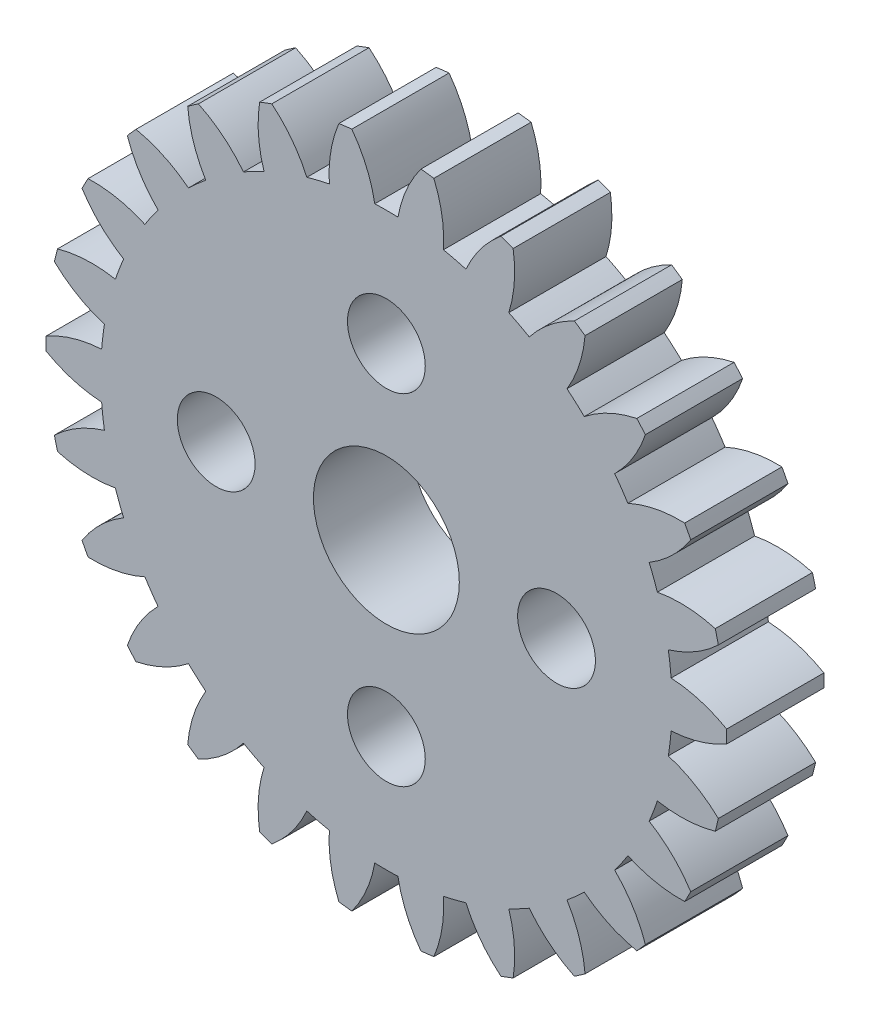
from build123d import *

# Parameters (mm, degrees)
SKETCH_1_R               = 14
EXTRUDE_1_DEPTH          = 4
CUT_EXTRUDE_1_DEPTH      = 4
PATTERN_CIRCULAR_1_COUNT = 26
CUT_EXTRUDE_2_REACH      = 6
SKETCH_3_R               = 3
SKETCH_3_R_2             = 1.6


with BuildPart() as part:
    # 草圖1 → 填料-伸長1 (new body)
    with BuildSketch(Plane.XY):
        Circle(SKETCH_1_R)
    extrude(amount=EXTRUDE_1_DEPTH)

    # 草圖2 → 除料-伸長1 (cut)
    with BuildSketch(Plane.XY.offset(4)):
        with BuildLine():
            ThreePointArc((-1.421594657, 13.927636865), (0, 14), (1.421594657, 13.927636865))
            ThreePointArc((1.421594657, 13.927636865), (0.822322703, 12.888806427), (0.476978653, 11.74031479))
            ThreePointArc((0.476978653, 11.74031479), (0, 11.75), (-0.476978653, 11.74031479))
            ThreePointArc((-0.476978653, 11.74031479), (-0.822322703, 12.888806427), (-1.421594657, 13.927636865))
        make_face()
    cut_extrude_1 = extrude(amount=-CUT_EXTRUDE_1_DEPTH, mode=Mode.SUBTRACT)

    # 環狀複製排列1: 除料-伸長1 ×26 about axis
    pattern_circular_1_axis = Axis((0, 0, 0), (0, 0, 1))
    for i in range(1, PATTERN_CIRCULAR_1_COUNT):
        add(cut_extrude_1.rotate(pattern_circular_1_axis, i * 360 / PATTERN_CIRCULAR_1_COUNT), mode=Mode.SUBTRACT)

    # 草圖3 → 除料-伸長2 (cut, up to next)
    with BuildSketch(Plane.XY.offset(4), mode=Mode.PRIVATE) as cut_extrude_2_sk1:
        Circle(SKETCH_3_R)
    cut_extrude_2_tool1 = extrude(cut_extrude_2_sk1.sketch, amount=-CUT_EXTRUDE_2_REACH, mode=Mode.PRIVATE) & part.part
    add(cut_extrude_2_tool1.solids().sort_by_distance((0, 0, 4))[0], mode=Mode.SUBTRACT)
    # 草圖3 → 除料-伸長2 (cut, up to next)
    with BuildSketch(Plane.XY.offset(4), mode=Mode.PRIVATE) as cut_extrude_2_sk2:
        with Locations((0, 7)):
            Circle(SKETCH_3_R_2)
    cut_extrude_2_tool2 = extrude(cut_extrude_2_sk2.sketch, amount=-CUT_EXTRUDE_2_REACH, mode=Mode.PRIVATE) & part.part
    add(cut_extrude_2_tool2.solids().sort_by_distance((0, 7, 4))[0], mode=Mode.SUBTRACT)
    # 草圖3 → 除料-伸長2 (cut, up to next)
    with BuildSketch(Plane.XY.offset(4), mode=Mode.PRIVATE) as cut_extrude_2_sk3:
        with Locations((7, 0)):
            Circle(SKETCH_3_R_2)
    cut_extrude_2_tool3 = extrude(cut_extrude_2_sk3.sketch, amount=-CUT_EXTRUDE_2_REACH, mode=Mode.PRIVATE) & part.part
    add(cut_extrude_2_tool3.solids().sort_by_distance((7, 0, 4))[0], mode=Mode.SUBTRACT)
    # 草圖3 → 除料-伸長2 (cut, up to next)
    with BuildSketch(Plane.XY.offset(4), mode=Mode.PRIVATE) as cut_extrude_2_sk4:
        with Locations((0, -7)):
            Circle(SKETCH_3_R_2)
    cut_extrude_2_tool4 = extrude(cut_extrude_2_sk4.sketch, amount=-CUT_EXTRUDE_2_REACH, mode=Mode.PRIVATE) & part.part
    add(cut_extrude_2_tool4.solids().sort_by_distance((0, -7, 4))[0], mode=Mode.SUBTRACT)
    # 草圖3 → 除料-伸長2 (cut, up to next)
    with BuildSketch(Plane.XY.offset(4), mode=Mode.PRIVATE) as cut_extrude_2_sk5:
        with Locations((-7, 0)):
            Circle(SKETCH_3_R_2)
    cut_extrude_2_tool5 = extrude(cut_extrude_2_sk5.sketch, amount=-CUT_EXTRUDE_2_REACH, mode=Mode.PRIVATE) & part.part
    add(cut_extrude_2_tool5.solids().sort_by_distance((-7, 0, 4))[0], mode=Mode.SUBTRACT)


solid = part.part
